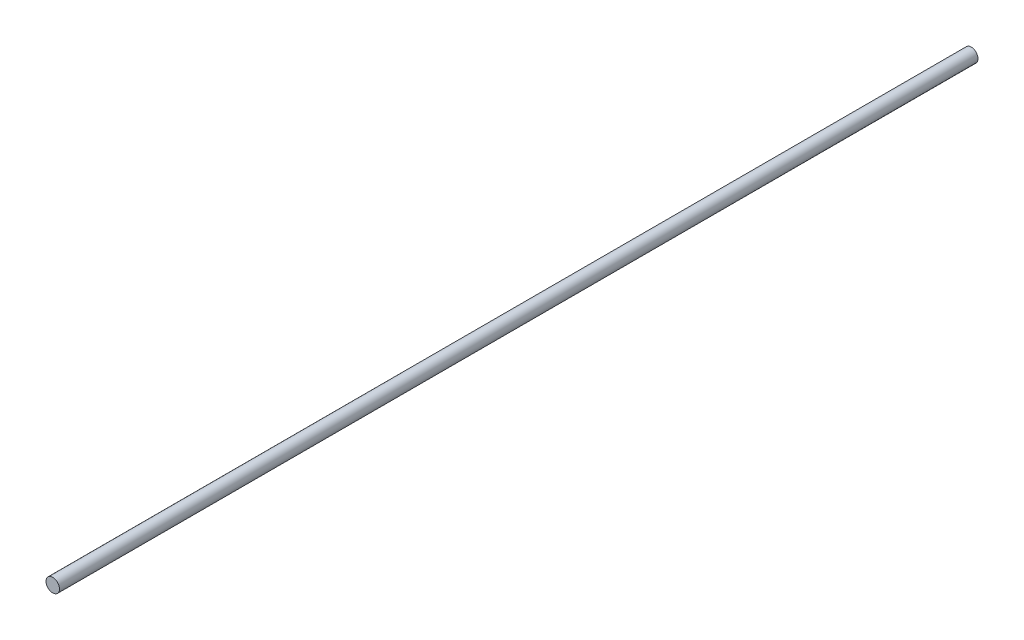
from build123d import *

# Parameters (mm, degrees)
SKETCH1_R           = 0.3175
BOSS_EXTRUDE1_DEPTH = 43.18


with BuildPart() as part:
    # Sketch1 → Boss-Extrude1 (new body)
    with BuildSketch(Plane.XY):
        Circle(SKETCH1_R)
    extrude(amount=BOSS_EXTRUDE1_DEPTH)


solid = part.part
